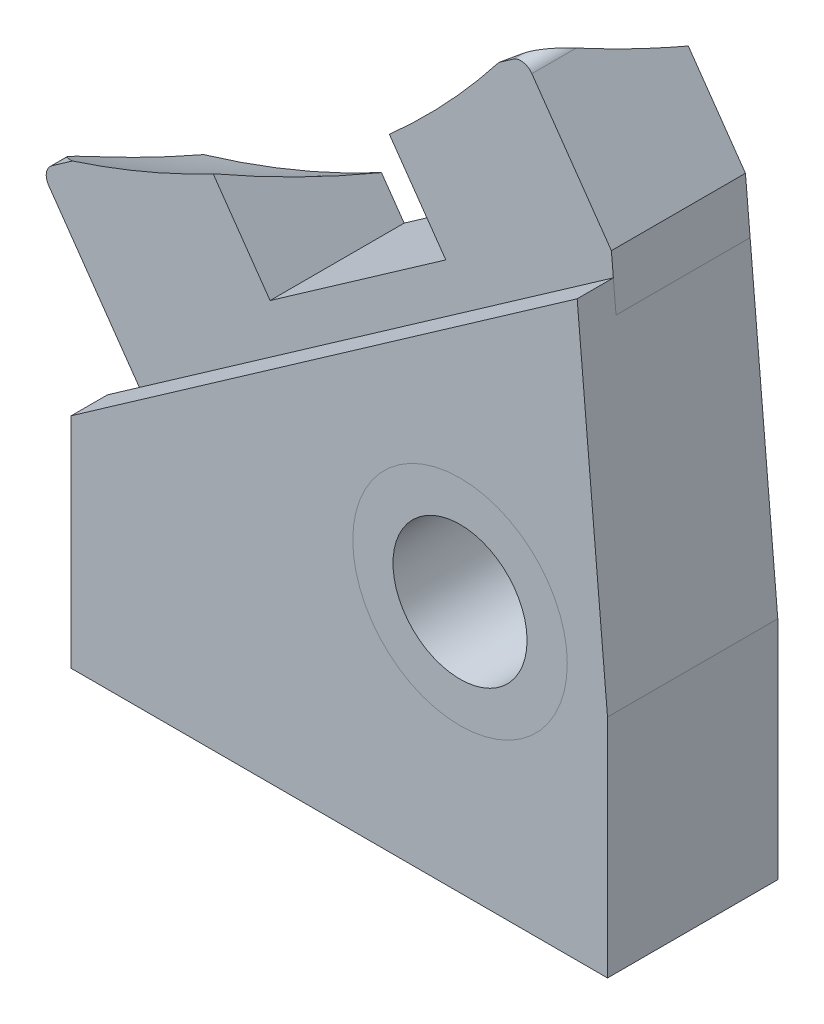
from build123d import *

# Parameters (mm, degrees)
SKIZZE1_R                       = 4
AUFSATZ_LINEAR_AUSTRAGEN1_DEPTH = 6.35
SKIZZE3_W                       = 27.712900838
SKIZZE3_H                       = 5
SCHNITT_LINEAR_AUSTRAGEN1_DEPTH = 1
AUFSATZ_LINEAR_AUSTRAGEN2_DEPTH = 5
SKIZZE6_R                       = 4
SKIZZE6_R_2                     = 2.5
AUFSATZ_LINEAR_AUSTRAGEN3_DEPTH = 6.35


with BuildPart() as part:
    # Skizze1 → Aufsatz-Linear austragen1 (new body)
    with BuildSketch(Plane.XY):
        Polygon((20, 8.428552255), (18.867770033, 21.37), (0, 8.158645194), (0, 0), (20, 0), align=None)
        with Locations((14.5, 9.4)):
            Circle(SKIZZE1_R, mode=Mode.SUBTRACT)
    extrude(amount=AUFSATZ_LINEAR_AUSTRAGEN1_DEPTH)

    # Skizze3 → Schnitt-Linear austragen1 (cut)
    with BuildSketch(Plane(origin=(-3.833309342, 5.474533096, 0), x_dir=(0.819152044, 0.573576436, 0), z_dir=(-0.573576436, 0.819152044, 0))):
        with Locations((13.856450419, -2.5)):
            Rectangle(SKIZZE3_W, SKIZZE3_H)
    extrude(amount=-SCHNITT_LINEAR_AUSTRAGEN1_DEPTH, mode=Mode.SUBTRACT)


with BuildPart() as body_2:
    # Skizze4 → Aufsatz-Linear austragen2 (new body)
    with BuildSketch(Plane(origin=(0, 0, 5), x_dir=(-1, 0, 0), z_dir=(0, 0, -1))):
        with BuildLine():
            Line((-18.79409733, 22.212082842), (-18.968408816, 20.219693446))
            Line((-18.968408816, 20.219693446), (-1.766215886, 8.174588282))
            Line((-1.766215886, 8.174588282), (2.191461525, 13.826737388))
            ThreePointArc((2.191461525, 13.826737388), (2.27428938, 14.200349695), (2.068673721, 14.523101628))
            Line((2.068673721, 14.523101628), (-3.255814567, 18.251348465))
            Line((-3.255814567, 18.251348465), (-6.066339105, 14.237503448))
            Line((-6.066339105, 14.237503448), (-12.619555459, 18.826114938))
            Line((-12.619555459, 18.826114938), (-9.809030921, 22.839959955))
            Line((-9.809030921, 22.839959955), (-15.133519209, 26.568206792))
            ThreePointArc((-15.133519209, 26.568206792), (-15.507131516, 26.651034646), (-15.829883449, 26.445418988))
            Line((-15.829883449, 26.445418988), (-18.79409733, 22.212082842))
        make_face()
    extrude(amount=AUFSATZ_LINEAR_AUSTRAGEN2_DEPTH)

    # Skizze5 → Schnitt-Rotation1 (revolve, cut)
    with BuildSketch(Plane.XY.offset(-12.575)):
        with BuildLine():
            Line((-48.8465, 46.47), (25.9465, 46.47))
            ThreePointArc((25.9465, 46.47), (-11.45, 9.0735), (-48.8465, 46.47))
        make_face()
    revolve(axis=Axis((-48.8465, 46.47, -12.575), (1, 0, 0)), mode=Mode.SUBTRACT)


with BuildPart() as body_3:
    # Skizze6 → Aufsatz-Linear austragen3 (new body)
    with BuildSketch(Plane.XY.offset(6.35)):
        with Locations((14.5, 9.4)):
            Circle(SKIZZE6_R)
        with Locations((14.5, 9.4)):
            Circle(SKIZZE6_R_2, mode=Mode.SUBTRACT)
    extrude(amount=-AUFSATZ_LINEAR_AUSTRAGEN3_DEPTH)


solid = Compound([part.part, body_2.part, body_3.part])
